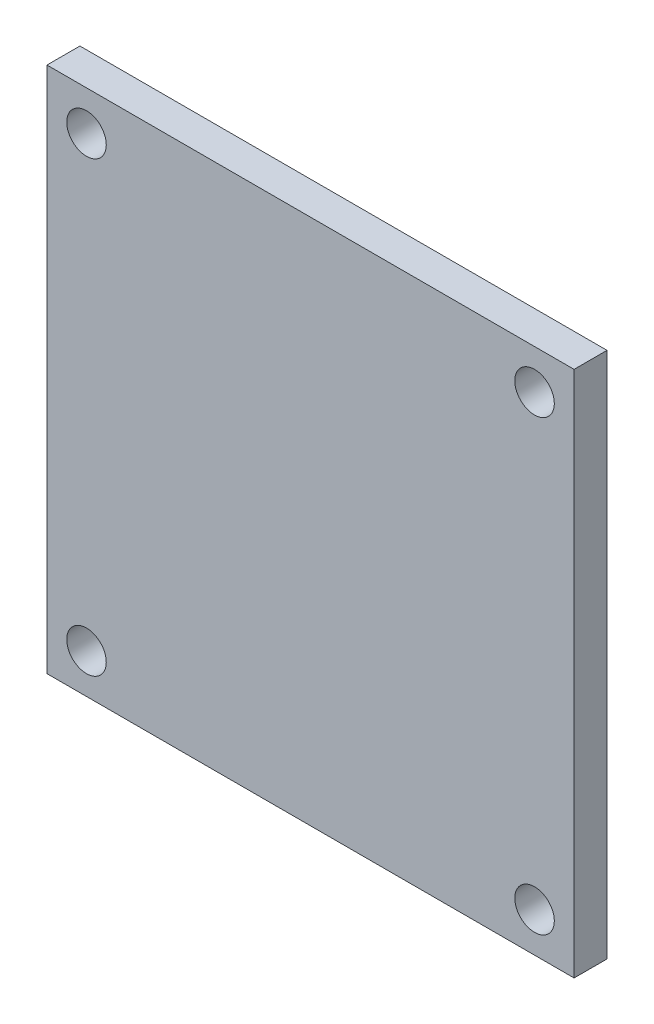
from build123d import *

# Parameters (mm, degrees)
SKETCH1_W           = 40
SKETCH1_H           = 40
BOSS_EXTRUDE1_DEPTH = 2.5
SKETCH2_R           = 1.5
CUT_EXTRUDE1_DEPTH  = 2.5


with BuildPart() as part:
    # Sketch1 → Boss-Extrude1 (new body)
    with BuildSketch(Plane.XY):
        with Locations((20, 20)):
            Rectangle(SKETCH1_W, SKETCH1_H)
    extrude(amount=BOSS_EXTRUDE1_DEPTH)

    # Sketch2 → Cut-Extrude1 (cut)
    with BuildSketch(Plane.XY.offset(2.5)):
        with Locations((3, 37)):
            Circle(SKETCH2_R)
        with Locations((37, 37)):
            Circle(SKETCH2_R)
        with Locations((37, 3)):
            Circle(SKETCH2_R)
        with Locations((3, 3)):
            Circle(SKETCH2_R)
    extrude(amount=-CUT_EXTRUDE1_DEPTH, mode=Mode.SUBTRACT)


solid = part.part
